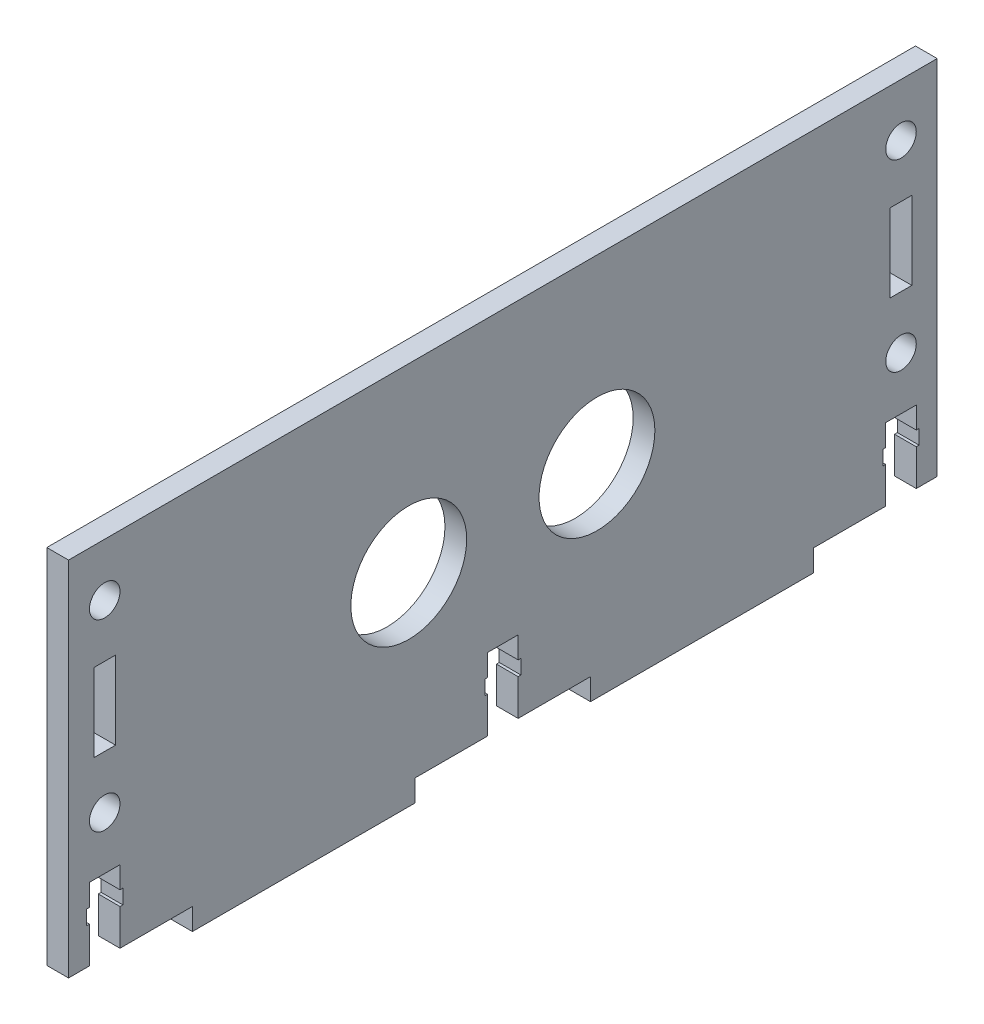
from build123d import *

# Parameters (mm, degrees)
SKETCH2_W                      = 3
SKETCH2_H                      = 10.78
BOSS_EXTRUDE2_DEPTH            = 3
HOLE_FOR_M3_300_SC_NUTS_SP_1_D = 4.22
SKETCH10_R                     = 8
CUT_EXTRUDE1_DEPTH             = 10


with BuildPart() as part:
    # Sketch2 → Boss-Extrude2 (new body)
    with BuildSketch(Plane(origin=(0, 0, 0), x_dir=(0, 0, -1), z_dir=(1, 0, 0))):
        Polygon((0, 0), (2.89, 0), (2.89, 5), (2.5, 5), (2.5, 7), (2.89, 7), (2.89, 10), (7.11, 10), (7.11, 7), (7.5, 7), (7.5, 5), (7.11, 5), (7.11, 0), (17.11, 0), (17.11, -3), (47.89, -3), (47.89, 0), (57.89, 0), (57.89, 5), (57.5, 5), (57.5, 7), (57.89, 7), (57.89, 10), (62.11, 10), (62.11, 7), (62.5, 7), (62.5, 5), (62.11, 5), (62.11, 0), (72.11, 0), (72.11, -3), (102.89, -3), (102.89, 0), (112.89, 0), (112.89, 5), (112.5, 5), (112.5, 7), (112.89, 7), (112.89, 10), (117.11, 10), (117.11, 7), (117.5, 7), (117.5, 5), (117.11, 5), (117.11, 0), (120, 0), (120, 50), (0, 50), align=None)
        with Locations((115, 30)):
            Rectangle(SKETCH2_W, SKETCH2_H, mode=Mode.SUBTRACT)
        with Locations((5, 30)):
            Rectangle(SKETCH2_W, SKETCH2_H, mode=Mode.SUBTRACT)
    extrude(amount=BOSS_EXTRUDE2_DEPTH)

    # Hole for M3 300® SC Nuts (SP)1 (through all)
    with Locations(Plane(origin=(3, 0, 0), x_dir=(0, 0, -1), z_dir=(1, 0, 0))):
        with Locations((5, 42.695), (5, 17.305), (115, 42.695), (115, 17.305)):
            Hole(HOLE_FOR_M3_300_SC_NUTS_SP_1_D / 2)

    # Sketch10 → Cut-Extrude1 (cut)
    with BuildSketch(Plane(origin=(3, 0, 0), x_dir=(0, 0, -1), z_dir=(1, 0, 0))):
        with Locations((73, 25)):
            Circle(SKETCH10_R)
        with Locations((47, 25)):
            Circle(SKETCH10_R)
    extrude(amount=-CUT_EXTRUDE1_DEPTH, mode=Mode.SUBTRACT)


solid = part.part
